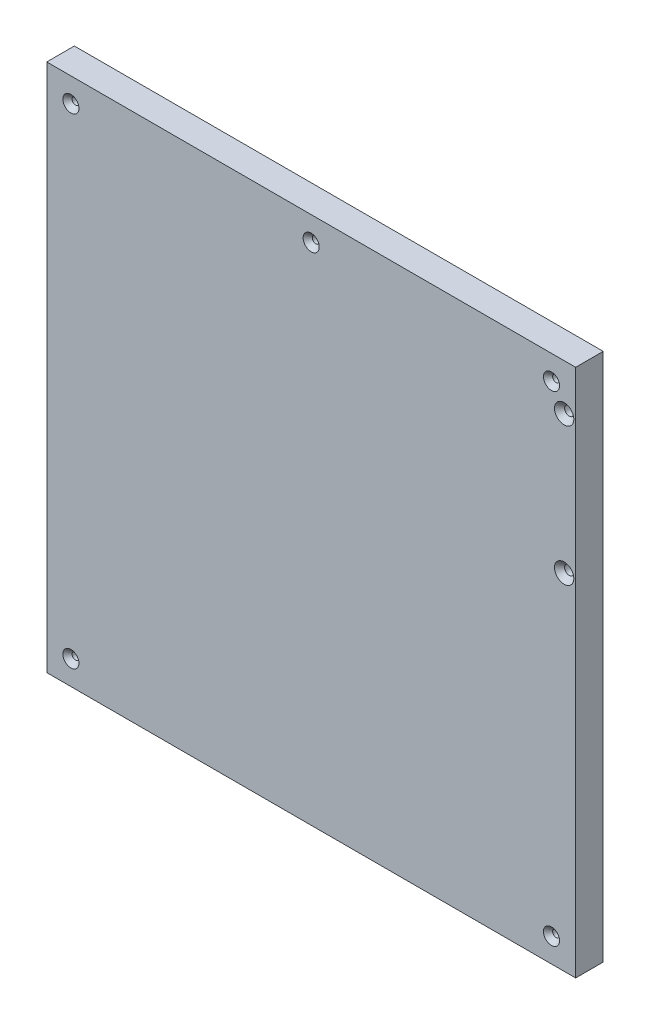
from build123d import *

# Parameters (mm, degrees)
SKETCH_1_W      = 230
SKETCH_1_H      = 230
SKETCH_1_R      = 1.5
SKETCH_1_R_2    = 2
EXTRUDE_1_DEPTH = 12
CHAMFER_1_SIZE  = 2
CHAMFER_2_SIZE  = 2.2


with BuildPart() as part:
    # Эскиз1 → Бобышка-Вытянуть1 (new body)
    with BuildSketch(Plane.XY):
        with Locations((115, 115)):
            Rectangle(SKETCH_1_W, SKETCH_1_H)
        with Locations((219.5, 10.5)):
            Circle(SKETCH_1_R, mode=Mode.SUBTRACT)
        with Locations((219.5, 219.5)):
            Circle(SKETCH_1_R, mode=Mode.SUBTRACT)
        with Locations((10.5, 219.5)):
            Circle(SKETCH_1_R, mode=Mode.SUBTRACT)
        with Locations((10.5, 10.5)):
            Circle(SKETCH_1_R, mode=Mode.SUBTRACT)
        with Locations((115, 219.5)):
            Circle(SKETCH_1_R, mode=Mode.SUBTRACT)
        with Locations((225, 150)):
            Circle(SKETCH_1_R_2, mode=Mode.SUBTRACT)
        with Locations((225, 210)):
            Circle(SKETCH_1_R_2, mode=Mode.SUBTRACT)
    extrude(amount=EXTRUDE_1_DEPTH)

    # Фаска1
    chamfer_1_edges = [part.edges().sort_by_distance(p)[0] for p in [
        (218, 10.5, 12),
        (218, 219.5, 12),
        (9, 219.5, 12),
        (9, 10.5, 12),
        (113.5, 219.5, 12),
    ]]
    chamfer(chamfer_1_edges, length=CHAMFER_1_SIZE)

    # Фаска2
    chamfer_2_edges = [part.edges().sort_by_distance(p)[0] for p in [
        (223, 150, 12),
        (223, 210, 12),
    ]]
    chamfer(chamfer_2_edges, length=CHAMFER_2_SIZE)


solid = part.part
